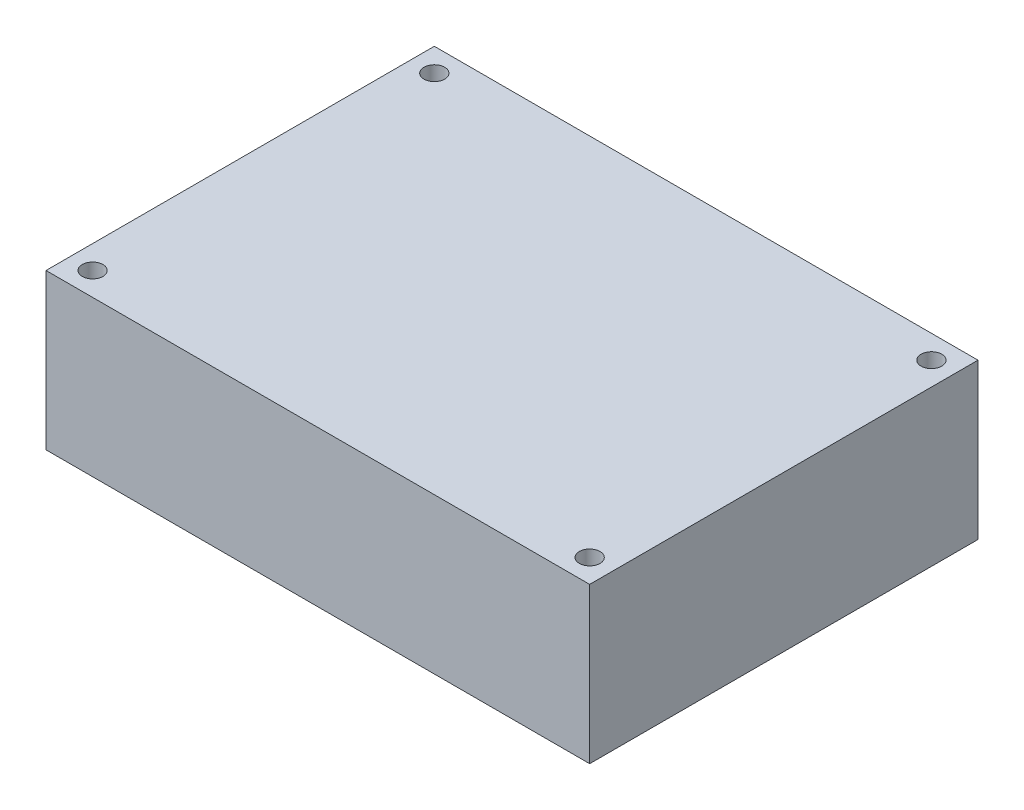
from build123d import *

# Parameters (mm, degrees)
SKETCH1_W             = 105
SKETCH1_H             = 75
BOSS_EXTRUDE1_DEPTH   = 15
F_4_0MM_DOWEL_HOLE1_D = 4


with BuildPart() as part:
    # Sketch1 → Boss-Extrude1 (new body, symmetric)
    with BuildSketch(Plane(origin=(0, 0, 0), x_dir=(1, 0, 0), z_dir=(0, 1, 0))):
        Rectangle(SKETCH1_W, SKETCH1_H)
    extrude(amount=BOSS_EXTRUDE1_DEPTH, both=True)

    # Ø4.0mm Dowel Hole1 (through all)
    with Locations(Plane(origin=(0, 15, 0), x_dir=(1, 0, 0), z_dir=(0, 1, 0))):
        with Locations((-48, 33), (48, 33), (48, -33), (-48, -33)):
            Hole(F_4_0MM_DOWEL_HOLE1_D / 2)


solid = part.part
